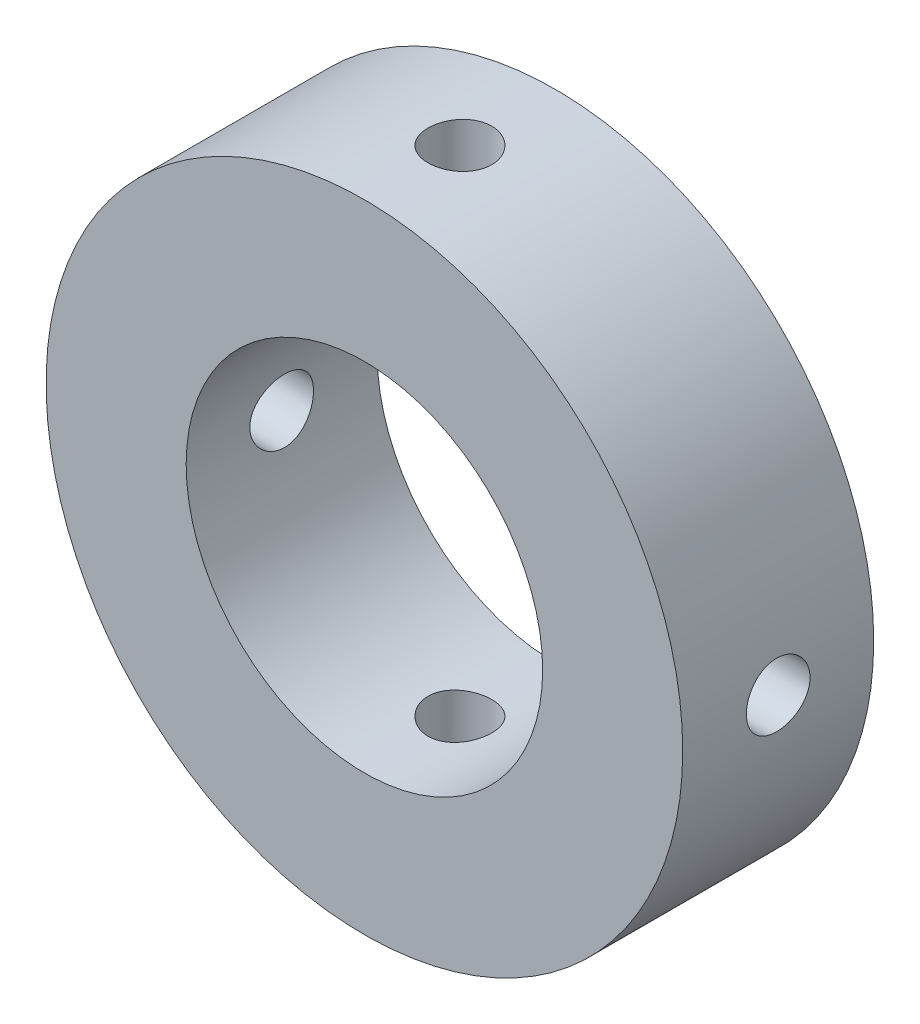
from build123d import *

# Parameters (mm, degrees)
SKETCH_1_R          = 5
SKETCH_1_R_2        = 2.8
EXTRUDE_1_DEPTH     = 3
SKETCH_2_R          = 0.5
CUT_EXTRUDE_1_DEPTH = 6.5
SKETCH_3_R          = 0.5
CUT_EXTRUDE_2_DEPTH = 6.5


with BuildPart() as part:
    # 草图1 → 凸台-拉伸1 (new body)
    with BuildSketch(Plane.XY):
        Circle(SKETCH_1_R)
        Circle(SKETCH_1_R_2, mode=Mode.SUBTRACT)
    extrude(amount=EXTRUDE_1_DEPTH)

    # 草图2 → 切除-拉伸1 (cut, symmetric)
    with BuildSketch(Plane(origin=(0, 0, 0), x_dir=(1, 0, 0), z_dir=(0, 1, 0))):
        with Locations((0, -1.5)):
            Circle(SKETCH_2_R)
    extrude(amount=CUT_EXTRUDE_1_DEPTH, both=True, mode=Mode.SUBTRACT)

    # 草图3 → 切除-拉伸2 (cut, symmetric)
    with BuildSketch(Plane(origin=(0, 0, 0), x_dir=(0, 0, -1), z_dir=(1, 0, 0))):
        with Locations((-1.5, 0)):
            Circle(SKETCH_3_R)
    extrude(amount=CUT_EXTRUDE_2_DEPTH, both=True, mode=Mode.SUBTRACT)


solid = part.part
